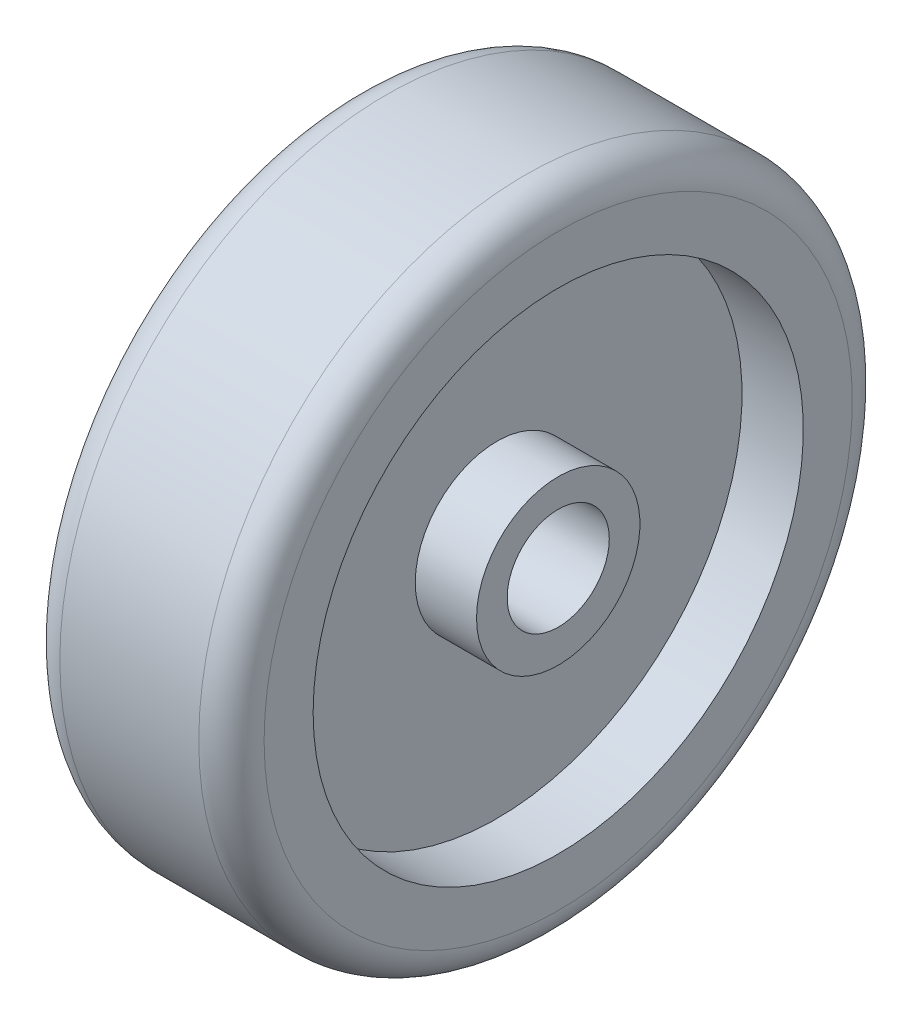
from build123d import *

# Parameters (mm, degrees)
SKETCH2_R          = 15.875
CUT_EXTRUDE1_DEPTH = 64.5
FILLET2_R          = 10.16
FILLET3_R          = 10.16


with BuildPart() as part:
    # Sketch1 → Revolve2 (revolve)
    with BuildSketch(Plane.XY):
        Polygon((-31.75, -0.729526652), (-31.75, 24.670473348), (-12.7, 24.670473348), (-12.7, 75.470473348), (-31.75, 75.470473348), (-31.75, 100.870473348), (31.75, 100.870473348), (31.75, 75.470473348), (12.7, 75.470473348), (12.7, 24.670473348), (31.75, 24.670473348), (31.75, -0.729526652), align=None)
    revolve(axis=Axis((-31.75, -0.729526652, 0), (1, 0, 0)))

    # Sketch2 → Cut-Extrude1 (cut, through all)
    with BuildSketch(Plane(origin=(31.75, 0, 0), x_dir=(0, 0, -1), z_dir=(1, 0, 0))):
        Circle(SKETCH2_R)
    extrude(amount=-CUT_EXTRUDE1_DEPTH, mode=Mode.SUBTRACT)

    # Fillet2
    fillet2_edges = [part.edges().sort_by_distance(p)[0] for p in [
        (31.75, -102.329526652, 0),
    ]]
    fillet(fillet2_edges, radius=FILLET2_R)

    # Fillet3
    fillet3_edges = [part.edges().sort_by_distance(p)[0] for p in [
        (-31.75, -102.329526652, 0),
    ]]
    fillet(fillet3_edges, radius=FILLET3_R)


solid = part.part
